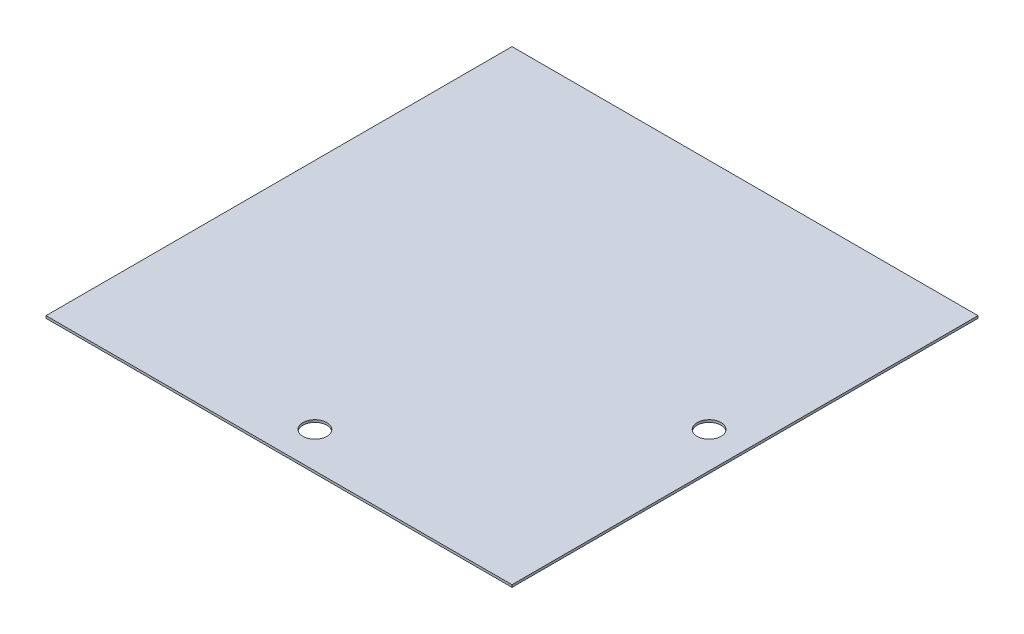
from build123d import *

# Parameters (mm, degrees)
SKETCH1_W           = 494.8428
SKETCH1_H           = 494.8428
BOSS_EXTRUDE1_DEPTH = 2.5
SKETCH2_R           = 12.7
CUT_EXTRUDE1_DEPTH  = 3.5


with BuildPart() as part:
    # Sketch1 → Boss-Extrude1 (new body)
    with BuildSketch(Plane(origin=(0, 0, 0), x_dir=(1, 0, 0), z_dir=(0, 1, 0))):
        Rectangle(SKETCH1_W, SKETCH1_H)
    extrude(amount=BOSS_EXTRUDE1_DEPTH)

    # Sketch2 → Cut-Extrude1 (cut, through all)
    with BuildSketch(Plane(origin=(0, 2.5, 0), x_dir=(1, 0, 0), z_dir=(0, 1, 0))):
        with Locations((209.3214, 0)):
            Circle(SKETCH2_R)
        with Locations((0, -209.3214)):
            Circle(SKETCH2_R)
    extrude(amount=-CUT_EXTRUDE1_DEPTH, mode=Mode.SUBTRACT)


solid = part.part
